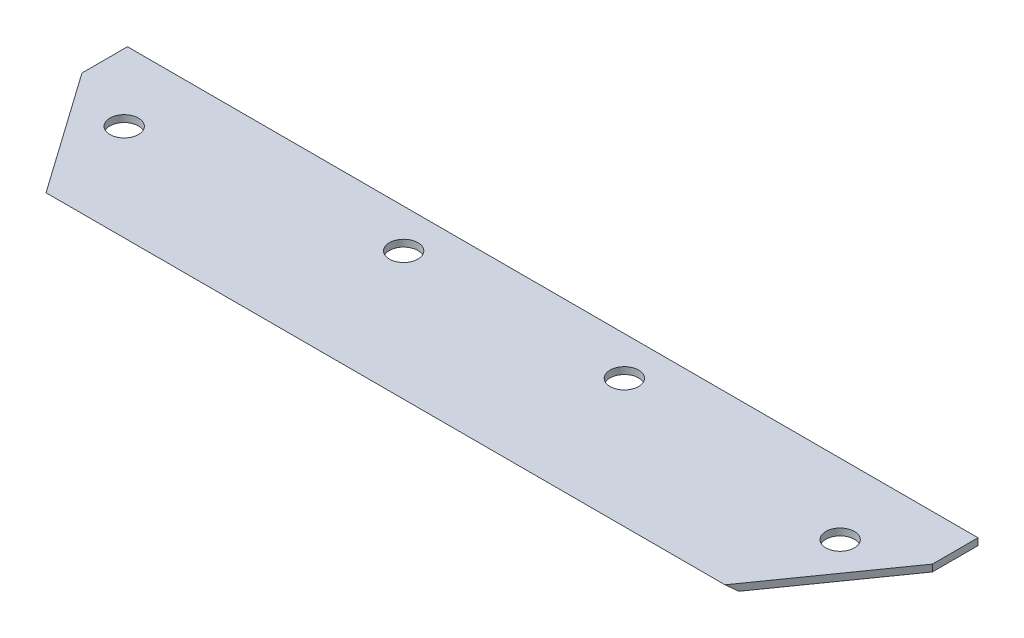
from build123d import *

# Parameters (mm, degrees)
SKETCH1_W            = 158
SKETCH1_H            = 43.5
BOSS_EXTRUDE1_DEPTH  = 1.27
CUT_EXTRUDE1_DEPTH   = 159
M5_CLEARANCE_HOLE1_D = 5.3
CUT_EXTRUDE2_DEPTH   = 2.27


with BuildPart() as part:
    # Sketch1 → Boss-Extrude1 (new body)
    with BuildSketch(Plane(origin=(0, 0, 0), x_dir=(1, 0, 0), z_dir=(0, 1, 0))):
        Rectangle(SKETCH1_W, SKETCH1_H)
    extrude(amount=BOSS_EXTRUDE1_DEPTH)

    # Sketch2 → Cut-Extrude1 (cut, through all)
    with BuildSketch(Plane(origin=(79, 0, 0), x_dir=(0, 0, -1), z_dir=(1, 0, 0))):
        Polygon((-22.585561228, 12.404199387), (-22.585561228, -1.620794398), (-5.871224499, -1.620794398), align=None)
    extrude(amount=-CUT_EXTRUDE1_DEPTH, mode=Mode.SUBTRACT)

    # M5 Clearance Hole1 (through all)
    with Locations(Plane(origin=(0, 1.27, 0), x_dir=(1, 0, 0), z_dir=(0, 1, 0))):
        with Locations((-66.5, 8.639185421), (-20.5, 14.555407289), (20.5, 14.555407289), (66.5, 8.639185421)):
            Hole(M5_CLEARANCE_HOLE1_D / 2)

    # Sketch5 → Cut-Extrude2 (cut, through all)
    with BuildSketch(Plane.XZ):
        Polygon((-79, -13.288842768), (-64.136558606, 7.802812046), (-59.820077438, 13.928024129), (-79, 13.928024129), align=None)
        Polygon((64.136558606, 7.802812046), (59.820077438, 13.928024129), (79, 13.928024129), (79, -13.288842768), align=None)
    extrude(amount=-CUT_EXTRUDE2_DEPTH, mode=Mode.SUBTRACT)


solid = part.part
